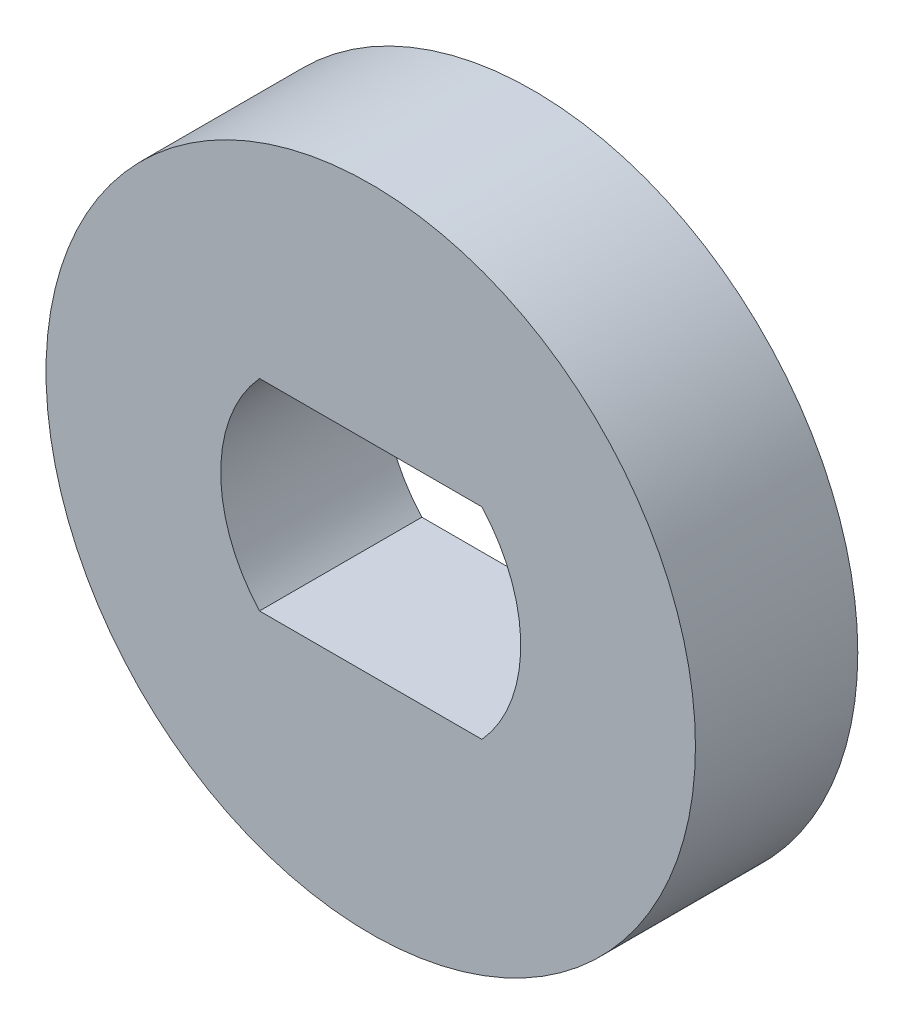
from build123d import *

# Parameters (mm, degrees)
SKETCH1_R           = 6.35
BOSS_EXTRUDE1_DEPTH = 3.175


with BuildPart() as part:
    # Sketch1 → Boss-Extrude1 (new body)
    with BuildSketch(Plane.XY):
        Circle(SKETCH1_R)
        with BuildLine():
            ThreePointArc((-2.175224917, 1.9685), (-2.9337, 0), (-2.175224917, -1.9685))
            Line((-2.175224917, -1.9685), (2.175224917, -1.9685))
            ThreePointArc((2.175224917, -1.9685), (2.9337, 0), (2.175224917, 1.9685))
            Line((2.175224917, 1.9685), (-2.175224917, 1.9685))
        make_face(mode=Mode.SUBTRACT)
    extrude(amount=BOSS_EXTRUDE1_DEPTH)


solid = part.part
